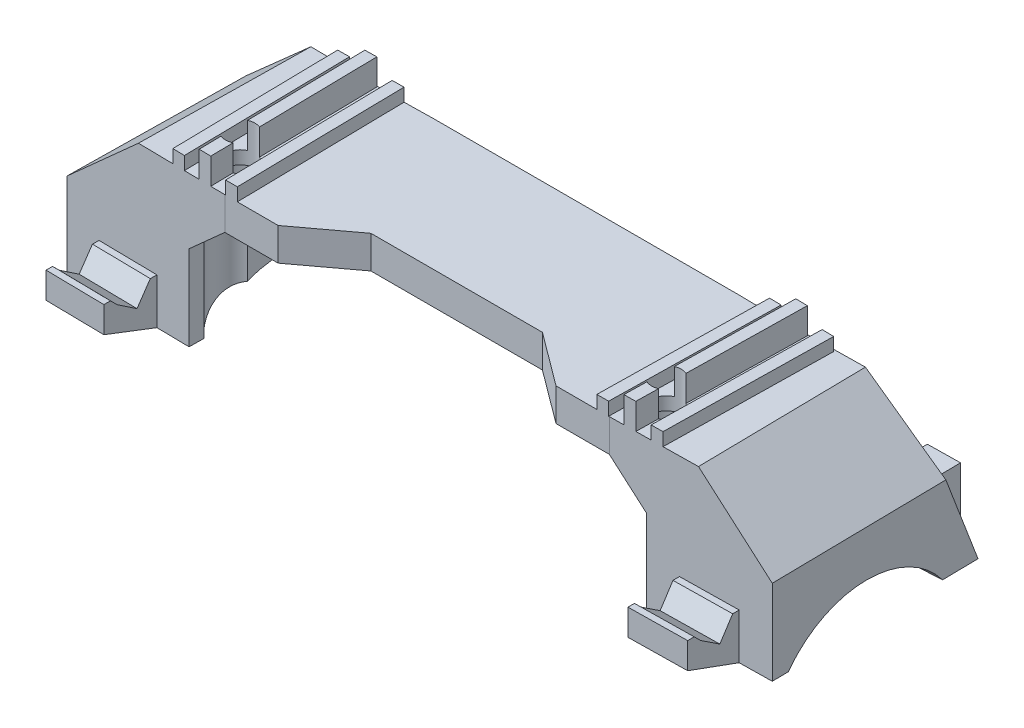
from build123d import *

# Parameters (mm, degrees)
BOSS_EXTRUDE1_DEPTH     = 5
BOSS_EXTRUDE2_DEPTH     = 4
BOSS_EXTRUDE3_DEPTH     = 2
BOSS_EXTRUDE4_DEPTH     = 2
BOSS_EXTRUDE5_DEPTH     = 5
BOSS_EXTRUDE6_DEPTH     = 4
BOSS_EXTRUDE7_DEPTH     = 2
BOSS_EXTRUDE8_DEPTH     = 2
BOSS_EXTRUDE9_DEPTH     = 5
BOSS_EXTRUDE10_DEPTH    = 13
CUT_EXTRUDE6_START      = 0.184083
SKETCH15_R              = 15
CUT_EXTRUDE6_DEPTH      = 19.151101
CUT_EXTRUDE7_DEPTH      = 19
BOSS_EXTRUDE12_DEPTH    = 7
CUT_EXTRUDE12_DEPTH     = 6
SKETCH26_R              = 3
CUT_EXTRUDE14_DEPTH     = 9
CUT_EXTRUDE16_DEPTH     = 13
CUT_EXTRUDE17_DEPTH     = 13
BOSS_EXTRUDE15_DEPTH    = 7
BOSS_EXTRUDE13_DEPTH    = 13
CUT_EXTRUDE10_START     = 0.368421
SKETCH21_R              = 15
CUT_EXTRUDE10_DEPTH     = 19.288583
CUT_EXTRUDE11_DEPTH     = 19
CUT_EXTRUDE21_DEPTH     = 9
CUT_EXTRUDE22_DEPTH     = 9
BOSS_EXTRUDE14_DEPTH    = 7
CUT_EXTRUDE13_DEPTH     = 6
SKETCH27_R              = 3
CUT_EXTRUDE15_DEPTH     = 9
CUT_EXTRUDE18_DEPTH     = 13
CUT_EXTRUDE19_DEPTH     = 13
BOSS_EXTRUDE16_DEPTH    = 7
CUT_EXTRUDE20_DEPTH     = 9
CUT_EXTRUDE23_DEPTH     = 9
BOSS_EXTRUDE17_DEPTH    = 27
BOSS_EXTRUDE18_DEPTH    = 27
CUT_EXTRUDE27_DEPTH     = 24.562908
CUT_EXTRUDE28_DEPTH     = 24.562908
CUT_EXTRUDE26_DEPTH     = 9
SKETCH5_R               = 2.25
CUT_EXTRUDE1_DEPTH      = 9
SKETCH6_R               = 4
CUT_EXTRUDE2_DEPTH      = 19.0000001
CUT_EXTRUDE2_DEPTH_BACK = 3
SKETCH11_R              = 2.25
CUT_EXTRUDE3_DEPTH      = 9
SKETCH12_R              = 4
CUT_EXTRUDE5_DEPTH      = 3
CUT_EXTRUDE5_DEPTH_BACK = 19.000000102


with BuildPart() as part:
    # Sketch1 → Boss-Extrude1 (new body)
    with BuildSketch(Plane(origin=(0, 0, 0), x_dir=(1, 0, 0), z_dir=(0, 1, 0))):
        Polygon((-41.997106208, 0), (-23, 0.331595722), (-23.477323316, 27.677430185), (-42.474429524, 27.345834463), align=None)
    extrude(amount=-BOSS_EXTRUDE1_DEPTH)

    # Sketch2 → Boss-Extrude2 (add)
    with BuildSketch(Plane(origin=(0, 0, 0), x_dir=(1, 0, 0), z_dir=(0, 1, 0))):
        Polygon((-33.39841603, 0.150090695), (-33.875739346, 27.495925158), (-32.076013494, 27.527339489), (-31.598690178, 0.181505027), align=None)
    extrude(amount=BOSS_EXTRUDE2_DEPTH)

    # Sketch3 → Boss-Extrude3 (add)
    with BuildSketch(Plane(origin=(0, 0, 0), x_dir=(1, 0, 0), z_dir=(0, 1, 0))):
        Polygon((-37.975114896, 27.424370291), (-36.175389045, 27.455784623), (-35.698065728, 0.109950161), (-37.49779158, 0.078535829), align=None)
    extrude(amount=BOSS_EXTRUDE3_DEPTH)

    # Sketch4 → Boss-Extrude4 (add)
    with BuildSketch(Plane(origin=(0, 0, 0), x_dir=(1, 0, 0), z_dir=(0, 1, 0))):
        Polygon((-29.776363796, 27.567480024), (-27.976637944, 27.598894356), (-27.499314628, 0.253059893), (-29.299040479, 0.221645562), align=None)
    extrude(amount=BOSS_EXTRUDE4_DEPTH)



with BuildPart() as body_2:
    # Sketch7 → Boss-Extrude5 (new body)
    with BuildSketch(Plane(origin=(0, 0, 0), x_dir=(1, 0, 0), z_dir=(0, 1, 0))):
        Polygon((23, 0.331595722), (41.997106208, 0), (42.474429524, 27.345834463), (23.477323316, 27.677430185), align=None)
    extrude(amount=-BOSS_EXTRUDE5_DEPTH)

    # Sketch8 → Boss-Extrude6 (add)
    with BuildSketch(Plane(origin=(0, 0, 0), x_dir=(-1, 0, 0), z_dir=(0, -1, 0))):
        Polygon((-31.598690178, 0.181505027), (-32.076013494, 27.527339489), (-33.875739346, 27.495925158), (-33.39841603, 0.150090695), align=None)
    extrude(amount=-BOSS_EXTRUDE6_DEPTH)

    # Sketch9 → Boss-Extrude7 (add)
    with BuildSketch(Plane(origin=(0, 0, 0), x_dir=(-1, 0, 0), z_dir=(0, -1, 0))):
        Polygon((-37.49779158, 0.078535829), (-37.975114896, 27.424370291), (-36.175389045, 27.455784623), (-35.698065728, 0.109950161), align=None)
    extrude(amount=-BOSS_EXTRUDE7_DEPTH)

    # Sketch10 → Boss-Extrude8 (add)
    with BuildSketch(Plane(origin=(0, 0, 0), x_dir=(-1, 0, 0), z_dir=(0, -1, 0))):
        Polygon((-27.499314628, 0.253059893), (-27.976637944, 27.598894356), (-29.776363796, 27.567480024), (-29.299040479, 0.221645562), align=None)
    extrude(amount=-BOSS_EXTRUDE8_DEPTH)


with BuildPart() as part_1:
    add(part.part)

    add(body_2.part)  # Boss-Extrude9 merges body 2
    # Sketch13 → Boss-Extrude9 (add)
    with BuildSketch(Plane(origin=(0, 0, 0), x_dir=(1, 0, 0), z_dir=(0, 1, 0))):
        Polygon((23, 0.331595722), (23.477323316, 27.677430185), (-23.477323316, 27.677430185), (-23, 0.331595722), (-13.126698737, 7.677430185), (13.126698737, 7.677430185), align=None)
    extrude(amount=-BOSS_EXTRUDE9_DEPTH)



with BuildPart() as body_2_2:
    # Sketch14 → Boss-Extrude10 (new body)
    with BuildSketch(Plane(origin=(0, -10, 0), x_dir=(1, 0, 0), z_dir=(0, 1, 0))):
        Polygon((-53.997680522, 2), (-35, 1.703125), (-34.5, 33.699218512), (-53.497680522, 33.996093512), align=None)
    extrude(amount=-BOSS_EXTRUDE10_DEPTH)

    # Sketch15 → Cut-Extrude6 (cut)
    with BuildSketch(Plane(origin=(-54.278596607, -19.996543976, -0.848206619), x_dir=(-0.015625, 0, 0.999877922), z_dir=(0.999532362, -0.026288502, 0.0156196)).offset(CUT_EXTRUDE6_START)):
        with Locations((-15.656042086, 12)):
            Circle(SKETCH15_R)
    extrude(amount=CUT_EXTRUDE6_DEPTH, mode=Mode.SUBTRACT)

    # Sketch16 → Cut-Extrude7 (cut)
    with BuildSketch(Plane(origin=(-54.01574368, 0, -0.844099041), x_dir=(-0.015625, 0, 0.999877922), z_dir=(-0.999877922, 0, -0.015625))):
        Polygon((-33.156042086, -23), (-28.156042086, -10), (-33.156042086, -10), align=None)
    extrude(amount=-CUT_EXTRUDE7_DEPTH, mode=Mode.SUBTRACT)

    # Sketch18 → Boss-Extrude12 (add)
    with BuildSketch(Plane.XZ.offset(23)):
        Polygon((-46.428222567, -38.386169162), (-46.568847567, -29.387267861), (-41.569457956, -29.309142861), (-41.428832956, -38.308044162), align=None)
    extrude(amount=-BOSS_EXTRUDE12_DEPTH)

    # Sketch24 → Cut-Extrude12 (cut)
    with BuildSketch(Plane(origin=(0, -10, 0), x_dir=(1, 0, 0), z_dir=(0, 1, 0))):
        Polygon((-48.576415911, 28.9185789), (-48.498290911, 33.917968512), (-39.499389611, 33.777343512), (-39.577514611, 28.7779539), align=None)
    extrude(amount=-CUT_EXTRUDE12_DEPTH, mode=Mode.SUBTRACT)

    # Sketch26 → Cut-Extrude14 (cut)
    with BuildSketch(Plane(origin=(-49.016354069, 0, -0.765974041), x_dir=(0.015625, 0, -0.999877922), z_dir=(0.999877922, 0, 0.015625))):
        with Locations((31.156042086, -16)):
            Circle(SKETCH26_R)
    extrude(amount=CUT_EXTRUDE14_DEPTH, mode=Mode.SUBTRACT)

    # Sketch30 → Cut-Extrude16 (cut)
    with BuildSketch(Plane(origin=(0, -10, 0), x_dir=(1, 0, 0), z_dir=(0, 1, 0))):
        with BuildLine():
            Line((-50.545165911, 30.918334745), (-50.49780263, 33.949214697))
            Line((-50.49780263, 33.949214697), (-46.498779193, 33.886722326))
            Line((-46.498779193, 33.886722326), (-46.545165911, 30.918334745))
            ThreePointArc((-46.545165911, 30.918334745), (-48.545165911, 28.918334745), (-50.545165911, 30.918334745))
        make_face()
    extrude(amount=-CUT_EXTRUDE16_DEPTH, mode=Mode.SUBTRACT)

    # Sketch31 → Cut-Extrude17 (cut)
    with BuildSketch(Plane(origin=(0, -10, 0), x_dir=(1, 0, 0), z_dir=(0, 1, 0))):
        with BuildLine():
            Line((-37.546508767, 30.746459745), (-37.499633767, 33.746093512))
            Line((-37.499633767, 33.746093512), (-41.499145456, 33.808593512))
            Line((-41.499145456, 33.808593512), (-41.546020456, 30.808959745))
            ThreePointArc((-41.546020456, 30.808959745), (-39.577514611, 28.7779539), (-37.546508767, 30.746459745))
        make_face()
    extrude(amount=-CUT_EXTRUDE17_DEPTH, mode=Mode.SUBTRACT)

    # Sketch34 → Boss-Extrude15 (add)
    with BuildSketch(Plane.XZ.offset(23)):
        Polygon((-48.998290911, -1.921875), (-49.123290911, 6.077148378), (-40.124389611, 6.217773378), (-39.999389611, -1.78125), align=None)
    extrude(amount=-BOSS_EXTRUDE15_DEPTH)

    # Sketch37 → Cut-Extrude21 (cut)
    with BuildSketch(Plane(origin=(-49.016354069, 0, -0.765974041), x_dir=(-0.015625, 0, 0.999877922), z_dir=(-0.999877922, 0, -0.015625))):
        Polygon((-1.156042086, -23), (6.843957914, -20), (6.843957914, -23), align=None)
    extrude(amount=-CUT_EXTRUDE21_DEPTH, mode=Mode.SUBTRACT)

    # Sketch38 → Cut-Extrude22 (cut)
    with BuildSketch(Plane(origin=(-49.016354069, 0, -0.765974041), x_dir=(-0.015625, 0, 0.999877922), z_dir=(-0.999877922, 0, -0.015625))):
        Polygon((5.843957914, -16), (4.843957914, -17), (1.843957914, -19), (-0.156042086, -16), align=None)
    extrude(amount=-CUT_EXTRUDE22_DEPTH, mode=Mode.SUBTRACT)


with BuildPart() as body_3:
    # Sketch20 → Boss-Extrude13 (new body)
    with BuildSketch(Plane(origin=(0, -10, 0), x_dir=(1, 0, 0), z_dir=(0, 1, 0))):
        Polygon((35, 1.703125), (53.997680522, 2), (53.497680522, 33.996093512), (34.5, 33.699218512), align=None)
    extrude(amount=-BOSS_EXTRUDE13_DEPTH)

    # Sketch21 → Cut-Extrude10 (cut)
    with BuildSketch(Plane(origin=(54.541267849, -19.986178293, -0.852311358), x_dir=(-0.015625, 0, -0.999877922), z_dir=(-0.99849592, -0.052558833, 0.015603404)).offset(CUT_EXTRUDE10_START)):
        with Locations((15.656042086, 12)):
            Circle(SKETCH21_R)
    extrude(amount=CUT_EXTRUDE10_DEPTH, mode=Mode.SUBTRACT)

    # Sketch22 → Cut-Extrude11 (cut)
    with BuildSketch(Plane(origin=(54.01574368, 0, -0.844099041), x_dir=(-0.015625, 0, -0.999877922), z_dir=(0.999877922, 0, -0.015625))):
        Polygon((33.156042086, -23), (28.156042086, -10), (33.156042086, -10), align=None)
    extrude(amount=-CUT_EXTRUDE11_DEPTH, mode=Mode.SUBTRACT)

    # Sketch23 → Boss-Extrude14 (add)
    with BuildSketch(Plane.XZ.offset(23)):
        Polygon((41.569457956, -29.309142861), (46.568847567, -29.387267861), (46.428222567, -38.386169162), (41.428832956, -38.308044162), align=None)
    extrude(amount=-BOSS_EXTRUDE14_DEPTH)

    # Sketch25 → Cut-Extrude13 (cut)
    with BuildSketch(Plane(origin=(0, -10, 0), x_dir=(1, 0, 0), z_dir=(0, 1, 0))):
        Polygon((39.577514611, 28.7779539), (48.576415911, 28.9185789), (48.498290911, 33.917968512), (39.499389611, 33.777343512), align=None)
    extrude(amount=-CUT_EXTRUDE13_DEPTH, mode=Mode.SUBTRACT)

    # Sketch27 → Cut-Extrude15 (cut)
    with BuildSketch(Plane(origin=(49.016354069, 0, -0.765974041), x_dir=(0.015625, 0, 0.999877922), z_dir=(-0.999877922, 0, 0.015625))):
        with Locations((-31.156042086, -16)):
            Circle(SKETCH27_R)
    extrude(amount=CUT_EXTRUDE15_DEPTH, mode=Mode.SUBTRACT)

    # Sketch32 → Cut-Extrude18 (cut)
    with BuildSketch(Plane(origin=(0, -10, 0), x_dir=(1, 0, 0), z_dir=(0, 1, 0))):
        with BuildLine():
            Line((46.545410067, 30.887084745), (46.498535067, 33.886718512))
            Line((46.498535067, 33.886718512), (50.498046756, 33.949218512))
            Line((50.498046756, 33.949218512), (50.544921756, 30.949584745))
            ThreePointArc((50.544921756, 30.949584745), (48.576415911, 28.9185789), (46.545410067, 30.887084745))
        make_face()
    extrude(amount=-CUT_EXTRUDE18_DEPTH, mode=Mode.SUBTRACT)

    # Sketch33 → Cut-Extrude19 (cut)
    with BuildSketch(Plane(origin=(0, -10, 0), x_dir=(1, 0, 0), z_dir=(0, 1, 0))):
        with BuildLine():
            Line((37.546508767, 30.746459745), (37.499633767, 33.746093512))
            Line((37.499633767, 33.746093512), (41.499145456, 33.808593512))
            Line((41.499145456, 33.808593512), (41.546020456, 30.808959745))
            ThreePointArc((41.546020456, 30.808959745), (39.577514611, 28.7779539), (37.546508767, 30.746459745))
        make_face()
    extrude(amount=-CUT_EXTRUDE19_DEPTH, mode=Mode.SUBTRACT)

    # Sketch35 → Boss-Extrude16 (add)
    with BuildSketch(Plane.XZ.offset(23)):
        Polygon((39.999389611, -1.78125), (40.124389611, 6.217773378), (49.123290911, 6.077148378), (48.998290911, -1.921875), align=None)
    extrude(amount=-BOSS_EXTRUDE16_DEPTH)

    # Sketch36 → Cut-Extrude20 (cut)
    with BuildSketch(Plane(origin=(49.016354069, 0, -0.765974041), x_dir=(-0.015625, 0, -0.999877922), z_dir=(0.999877922, 0, -0.015625))):
        Polygon((1.156042086, -23), (-6.843957914, -20), (-6.843957914, -23), align=None)
    extrude(amount=-CUT_EXTRUDE20_DEPTH, mode=Mode.SUBTRACT)

    # Sketch39 → Cut-Extrude23 (cut)
    with BuildSketch(Plane(origin=(49.016354069, 0, -0.765974041), x_dir=(-0.015625, 0, -0.999877922), z_dir=(0.999877922, 0, -0.015625))):
        Polygon((-5.843957914, -16), (-4.843957914, -17), (-1.843957914, -19), (0.156042086, -16), align=None)
    extrude(amount=-CUT_EXTRUDE23_DEPTH, mode=Mode.SUBTRACT)


with BuildPart() as part_2:
    add(part_1.part)

    add(body_2_2.part)  # Boss-Extrude17 merges body 2 2
    # Sketch41 → Boss-Extrude17 (add)
    with BuildSketch(Plane(origin=(-0.464955474, 0, -1.163449047), x_dir=(-0.999877922, 0, -0.015625), z_dir=(0.015625, 0, -0.999877922))):
        Polygon((42.413445399, 0), (53.539261002, -10), (34.539261002, -10), (28.9763532, -5), (28.9763532, 0), align=None)
    extrude(amount=BOSS_EXTRUDE17_DEPTH)


    add(body_3.part)  # Boss-Extrude18 merges body 3
    # Sketch42 → Boss-Extrude18 (add)
    with BuildSketch(Plane(origin=(0.464955474, 0, -1.163449047), x_dir=(-0.999877922, 0, 0.015625), z_dir=(-0.015625, 0, -0.999877922))):
        Polygon((-42.413445399, 0), (-53.539261002, -10), (-34.539261002, -10), (-28.9763532, -5), (-28.9763532, 0), align=None)
    extrude(amount=BOSS_EXTRUDE18_DEPTH)

    # Sketch48 → Cut-Extrude27 (cut)
    with BuildSketch(Plane(origin=(-54.01574368, 0, -0.844099041), x_dir=(-0.015625, 0, 0.999877922), z_dir=(-0.999877922, 0, -0.015625))):
        Polygon((-28.156042086, -10), (-28.156042086, 0), (-27.158390177, 0), align=None)
    extrude(amount=-CUT_EXTRUDE27_DEPTH, mode=Mode.SUBTRACT)

    # Sketch49 → Cut-Extrude28 (cut)
    with BuildSketch(Plane(origin=(54.01574368, 0, -0.844099041), x_dir=(-0.015625, 0, -0.999877922), z_dir=(0.999877922, 0, -0.015625))):
        Polygon((28.156042086, -10), (28.156042086, 0), (27.123479985, 0), align=None)
    extrude(amount=-CUT_EXTRUDE28_DEPTH, mode=Mode.SUBTRACT)

    # Sketch47 → Cut-Extrude26 (cut)
    with BuildSketch(Plane.XZ.offset(5)):
        Polygon((-44.498840261, -1.8515625), (-29.437771306, -1.616204566), (29.437771306, -1.616204566), (44.498840261, -1.8515625), (44.498840261, 3.1484375), (-44.498840261, 3.1484375), align=None)
    extrude(amount=-CUT_EXTRUDE26_DEPTH, mode=Mode.SUBTRACT)

    # Sketch5 → Cut-Extrude1 (cut)
    with BuildSketch(Plane(origin=(0, 4, 0), x_dir=(1, 0, 0), z_dir=(0, 1, 0))):
        with Locations((-32.620719949, 7.164731727)):
            Circle(SKETCH5_R)
    extrude(amount=-CUT_EXTRUDE1_DEPTH, mode=Mode.SUBTRACT)

    # Sketch6 → Cut-Extrude2 (cut, two sides)
    with BuildSketch(Plane.XZ.offset(5)) as cut_extrude2_sk:
        with Locations((-32.620719949, -7.164731727)):
            Circle(SKETCH6_R)
    extrude(amount=CUT_EXTRUDE2_DEPTH, mode=Mode.SUBTRACT)
    extrude(cut_extrude2_sk.sketch, amount=-CUT_EXTRUDE2_DEPTH_BACK, mode=Mode.SUBTRACT)

    # Sketch11 → Cut-Extrude3 (cut)
    with BuildSketch(Plane(origin=(0, 4, 0), x_dir=(1, 0, 0), z_dir=(0, 1, 0))):
        with Locations((32.620719949, 7.164731727)):
            Circle(SKETCH11_R)
    extrude(amount=-CUT_EXTRUDE3_DEPTH, mode=Mode.SUBTRACT)

    # Sketch12 → Cut-Extrude5 (cut, two sides)
    with BuildSketch(Plane(origin=(0, -5, 0), x_dir=(-1, 0, 0), z_dir=(0, 1, 0))) as cut_extrude5_sk:
        with Locations((-32.620719949, -7.164731727)):
            Circle(SKETCH12_R)
    extrude(amount=CUT_EXTRUDE5_DEPTH, mode=Mode.SUBTRACT)
    extrude(cut_extrude5_sk.sketch, amount=-CUT_EXTRUDE5_DEPTH_BACK, mode=Mode.SUBTRACT)


solid = part_2.part
